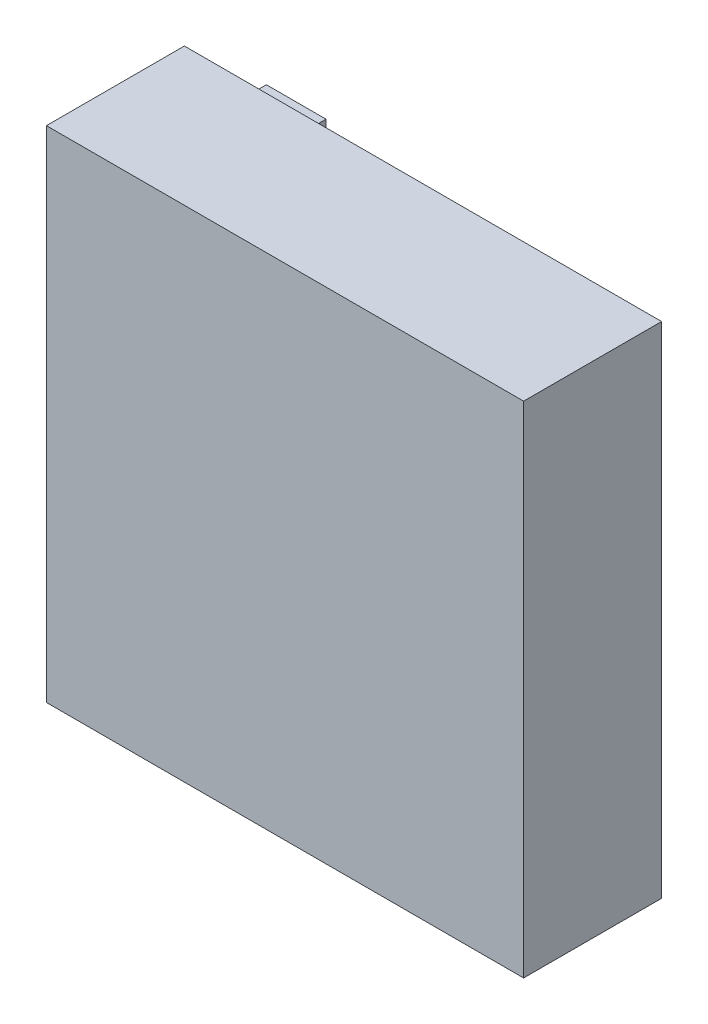
from build123d import *

# Parameters (mm, degrees)
ESQUISSE1_W        = 64
ESQUISSE1_H        = 67
BOSS_EXTRU_1_DEPTH = 18.5
ESQUISSE2_W        = 8
ESQUISSE2_H        = 4
BOSS_EXTRU_2_DEPTH = 4


with BuildPart() as part:
    # Esquisse1 → Boss.-Extru.1 (new body)
    with BuildSketch(Plane.XY):
        Rectangle(ESQUISSE1_W, ESQUISSE1_H)
    extrude(amount=BOSS_EXTRU_1_DEPTH)

    # Esquisse2 → Boss.-Extru.2 (add)
    with BuildSketch(Plane(origin=(0, 0, 0), x_dir=(-1, 0, 0), z_dir=(0, 0, -1))):
        with Locations((21, 28.5)):
            Rectangle(ESQUISSE2_W, ESQUISSE2_H)
    extrude(amount=BOSS_EXTRU_2_DEPTH)


solid = part.part
